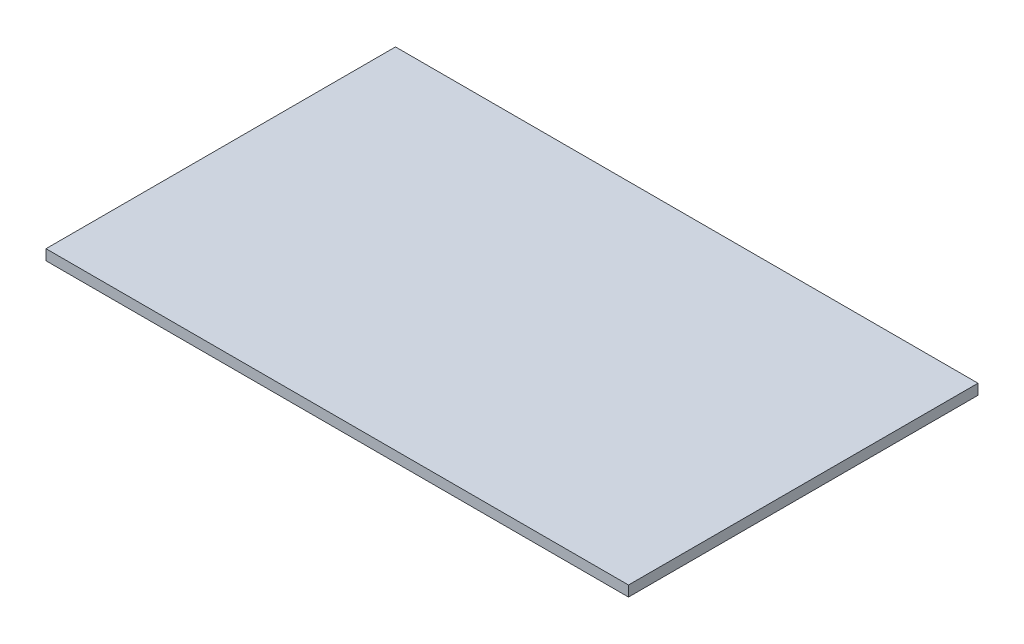
from build123d import *

# Parameters (mm, degrees)
SKETCH_1_W      = 1000
SKETCH_1_H      = 600
EXTRUDE_1_DEPTH = 18


with BuildPart() as part:
    # Эскиз1 → Бобышка-Вытянуть1 (new body)
    with BuildSketch(Plane(origin=(0, 0, 0), x_dir=(1, 0, 0), z_dir=(0, 1, 0))):
        with Locations((500, 300)):
            Rectangle(SKETCH_1_W, SKETCH_1_H)
    extrude(amount=EXTRUDE_1_DEPTH)


solid = part.part
